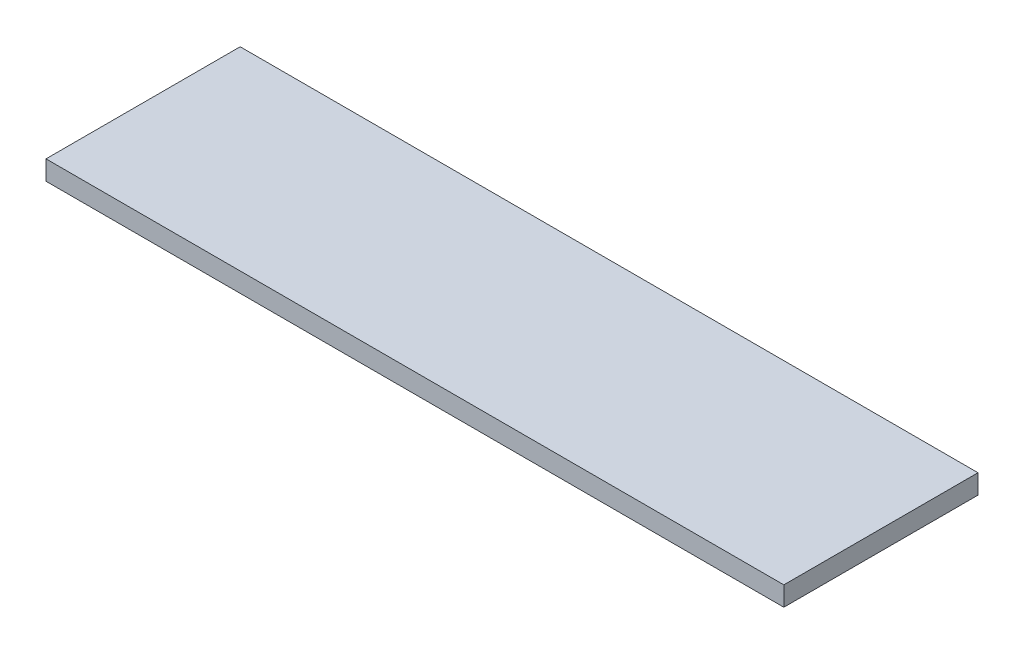
from build123d import *

# Parameters (mm, degrees)
SKETCH1_W           = 3800
SKETCH1_H           = 1000
BOSS_EXTRUDE1_DEPTH = 100


with BuildPart() as part:
    # Sketch1 → Boss-Extrude1 (new body)
    with BuildSketch(Plane(origin=(0, 0, 0), x_dir=(1, 0, 0), z_dir=(0, 1, 0))):
        with Locations((1900, 500)):
            Rectangle(SKETCH1_W, SKETCH1_H)
    extrude(amount=BOSS_EXTRUDE1_DEPTH)


solid = part.part
